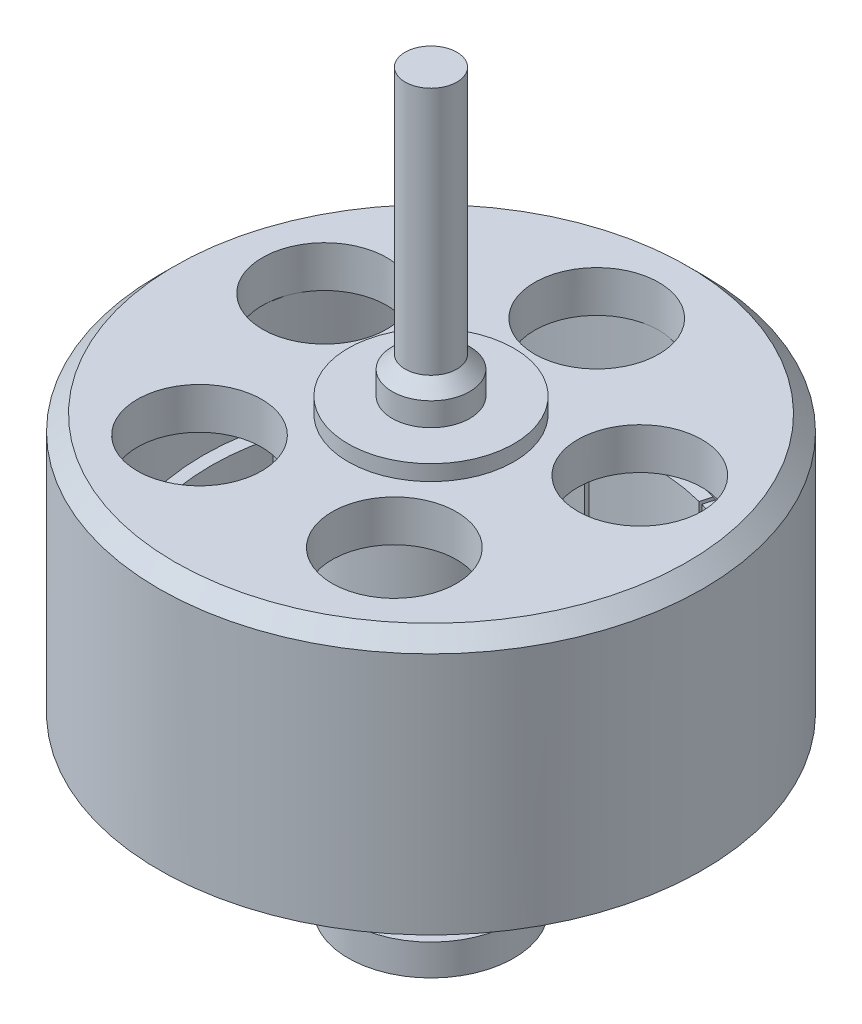
from build123d import *

# Parameters (mm, degrees)
SKETCH3_R           = 1.2
CUT_EXTRUDE1_DEPTH  = 6
BOSS_EXTRUDE1_START = -0.01
BOSS_EXTRUDE1_DEPTH = 2
CIRPATTERN1_COUNT   = 12
CHAMFER1_SIZE       = 0.3
SKETCH6_W           = 0.5
SKETCH6_H           = 14.8
SKETCH7_W           = 1.6
SKETCH7_H           = 0.6
SKETCH8_W           = 1.8
SKETCH8_H           = 1.5
SKETCH9_R           = 4.9
BOSS_EXTRUDE2_DEPTH = 2.09


with BuildPart() as part:
    # Sketch2 → Revolve1 (revolve)
    with BuildSketch(Plane(origin=(0, 0, 0), x_dir=(0, 0, -1), z_dir=(1, 0, 0))):
        Polygon((0, 2.1), (4.9, 2.1), (4.9, -2.1), (5.25, -2.1), (5.25, 2.9), (0, 2.9), align=None)
    revolve(axis=Axis((0, -2.1, 0), (0, 1, 0)))

    # Sketch3 → Cut-Extrude1 (cut, through all)
    with BuildSketch(Plane(origin=(0, 2.9, 0), x_dir=(1, 0, 0), z_dir=(0, 1, 0))):
        with Locations((0, 3.2)):
            Circle(SKETCH3_R)
        with Locations((3.043380852, 0.988854382)):
            Circle(SKETCH3_R)
        with Locations((1.880912807, -2.588854382)):
            Circle(SKETCH3_R)
        with Locations((-1.880912807, -2.588854382)):
            Circle(SKETCH3_R)
        with Locations((-3.043380852, 0.988854382)):
            Circle(SKETCH3_R)
    extrude(amount=-CUT_EXTRUDE1_DEPTH, mode=Mode.SUBTRACT)

    # Sketch4 → Boss-Extrude1 (add)
    with BuildSketch(Plane.XZ.offset(2.1).offset(BOSS_EXTRUDE1_START)):
        with BuildLine():
            Line((1.064115017, -4.114627472), (1.22686202, -4.743923438))
            ThreePointArc((1.22686202, -4.743923438), (0, -4.9), (-1.22686202, -4.743923438))
            Line((-1.22686202, -4.743923438), (-1.064115017, -4.114627472))
            ThreePointArc((-1.064115017, -4.114627472), (0, -4.25), (1.064115017, -4.114627472))
        make_face()
    boss_extrude1 = extrude(amount=-BOSS_EXTRUDE1_DEPTH)

    # CirPattern1: Boss-Extrude1 ×12 about axis
    cirpattern1_axis = Axis((0, 0, 0), (0, 1, 0))
    for i in range(1, CIRPATTERN1_COUNT):
        add(boss_extrude1.rotate(cirpattern1_axis, i * 360 / CIRPATTERN1_COUNT))

    # Chamfer1
    chamfer1_edges = [part.edges().sort_by_distance(p)[0] for p in [
        (0, 2.9, 5.25),
    ]]
    chamfer(chamfer1_edges, length=CHAMFER1_SIZE)

    # Sketch6 → Revolve2 (revolve)
    with BuildSketch(Plane.XY):
        with Locations((0.25, 1.3)):
            Rectangle(SKETCH6_W, SKETCH6_H)
    revolve(axis=Axis((0, -6.1, 0), (0, 1, 0)))

    # Sketch7 → Revolve3 (revolve)
    with BuildSketch(Plane.XY):
        Polygon((0, 2.9), (1.6, 2.9), (1.6, 3.2), (0.75, 3.2), (0.75, 3.65), (0.5, 3.9), (0, 3.9), (0, 3.2), align=None)
        with Locations((0.8, -5.1)):
            Rectangle(SKETCH7_W, SKETCH7_H)
    revolve(axis=Axis((0, 3.2, 0), (0, 1, 0)))

    # Sketch8 → Revolve4 (revolve)
    with BuildSketch(Plane.XY):
        with Locations((0.9, 1.35)):
            Rectangle(SKETCH8_W, SKETCH8_H)
    revolve(axis=Axis((0, 2.1, 0), (0, -1, 0)))

    # Sketch9 → Boss-Extrude2 (add)
    with BuildSketch(Plane.XZ.offset(-2.1)):
        Circle(SKETCH9_R)
        with BuildLine():
            ThreePointArc((2.586255154, 3.559674743), (3.920428719, 1.997558174), (4.4, 0))
            ThreePointArc((4.4, 0), (4.345828698, -0.688311651), (4.184648669, -1.359674785))
            ThreePointArc((4.184648669, -1.359674785), (2.586255106, -3.559674778), (-1e-09, -4.4))
            ThreePointArc((-1e-09, -4.4), (-2.586255112, -3.559674774), (-4.184648673, -1.359674772))
            ThreePointArc((-4.184648673, -1.359674772), (-4.184648682, 1.359674743), (-2.586255168, 3.559674733))
            ThreePointArc((-2.586255168, 3.559674733), (-8e-09, 4.4), (2.586255154, 3.559674743))
        make_face(mode=Mode.SUBTRACT)
    extrude(amount=BOSS_EXTRUDE2_DEPTH)


solid = part.part
